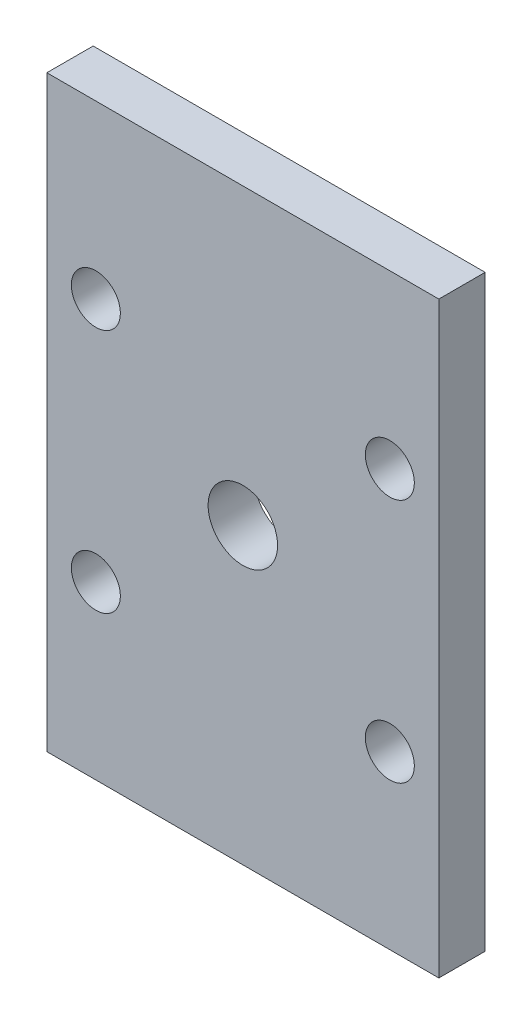
from build123d import *

# Parameters (mm, degrees)
SKETCH1_W                   = 50.8
SKETCH1_H                   = 76.2
BOSS_EXTRUDE1_DEPTH         = 6
F_1_4_0_25_DIAMETER_HOLE1_D = 6.35
SKETCH5_R                   = 4.5
CUT_EXTRUDE1_DEPTH          = 7


with BuildPart() as part:
    # Sketch1 → Boss-Extrude1 (new body)
    with BuildSketch(Plane.XY):
        with Locations((25.4, 38.1)):
            Rectangle(SKETCH1_W, SKETCH1_H)
    extrude(amount=BOSS_EXTRUDE1_DEPTH)

    # 1/4 (0.25) Diameter Hole1 (through all)
    with Locations(Plane.XY.offset(6)):
        with Locations((44.45, 53.975), (6.35, 53.975), (6.35, 22.225), (44.45, 22.225)):
            Hole(F_1_4_0_25_DIAMETER_HOLE1_D / 2)

    # Sketch5 → Cut-Extrude1 (cut, through all)
    with BuildSketch(Plane.XY.offset(6)):
        with Locations((25.4, 38.1)):
            Circle(SKETCH5_R)
    extrude(amount=-CUT_EXTRUDE1_DEPTH, mode=Mode.SUBTRACT)


solid = part.part
